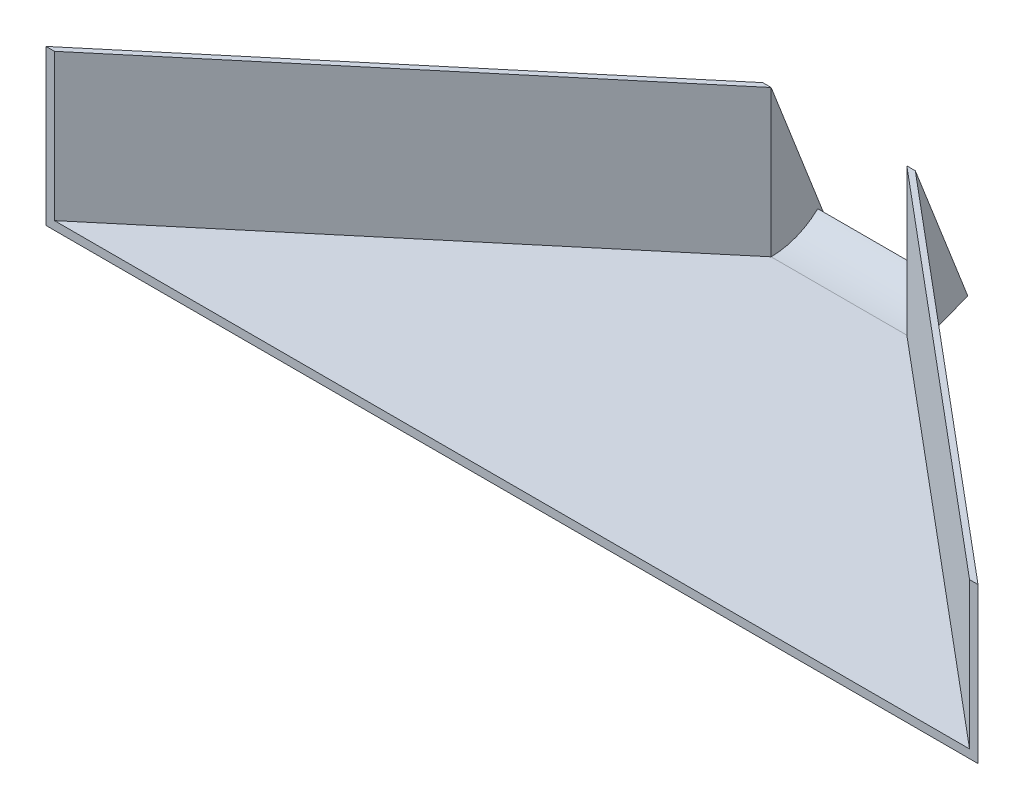
from build123d import *

# Parameters (mm, degrees)
BOSS_EXTRUDE1_DEPTH   = 2.7686
BOSS_EXTRUDE2_START   = -2.7686
BOSS_EXTRUDE2_DEPTH   = 50.8
BOSS_EXTRUDE2_2_DEPTH = 50.8
SKETCH4_W             = 2.7686
SKETCH4_H             = 50.8
BOSS_EXTRUDE3_DEPTH   = 25.4
CUT_EXTRUDE1_DEPTH    = 47.2186
BOSS_EXTRUDE6_DEPTH   = 44.45


with BuildPart() as part:
    # Sketch1 → Boss-Extrude1 (new body)
    with BuildSketch(Plane(origin=(0, 0, 0), x_dir=(1, 0, 0), z_dir=(0, 1, 0))):
        Polygon((0, 0), (44.45, 0), (172.085, -107.098481425), (-127.635, -107.098481425), align=None)
    extrude(amount=BOSS_EXTRUDE1_DEPTH)



with BuildPart() as body_2:
    # Sketch2 → Boss-Extrude2 (new body)
    with BuildSketch(Plane(origin=(0, 2.7686, 0), x_dir=(1, 0, 0), z_dir=(0, 1, 0)).offset(BOSS_EXTRUDE2_START)):
        Polygon((0, 0), (-127.635, -107.098481425), (-130.4036, -107.098481425), (-2.7686, 0), align=None)
    extrude(amount=BOSS_EXTRUDE2_DEPTH)


with BuildPart() as body_3:
    # Sketch2 → Boss-Extrude2 2 (new body)
    with BuildSketch(Plane(origin=(0, 2.7686, 0), x_dir=(1, 0, 0), z_dir=(0, 1, 0)).offset(BOSS_EXTRUDE2_START)):
        Polygon((44.45, 0), (47.2186, 0), (174.8536, -107.098481425), (172.085, -107.098481425), align=None)
    extrude(amount=BOSS_EXTRUDE2_2_DEPTH)


with BuildPart() as part_1:
    add(part.part)

    add(body_3.part)  # Boss-Extrude3 merges body 3
    # Sketch4 → Boss-Extrude3 (add)
    with BuildSketch(Plane(origin=(0, 0, 0), x_dir=(-1, 0, 0), z_dir=(0, 0, -1))):
        with Locations((-45.8343, 25.4)):
            Rectangle(SKETCH4_W, SKETCH4_H)
    boss_extrude3 = extrude(amount=BOSS_EXTRUDE3_DEPTH)

    # Sketch5 → Cut-Extrude1 (cut)
    with BuildSketch(Plane(origin=(47.2186, 0, 0), x_dir=(0, 0, -1), z_dir=(1, 0, 0))):
        Polygon((17.186035514, 6.697089394), (0, 0), (25.4, 0), (25.4, 14.244871038), (25.4, 50.8), (0, 50.8), align=None)
    cut_extrude1 = extrude(amount=-CUT_EXTRUDE1_DEPTH, mode=Mode.SUBTRACT)


    add(body_2.part)  # Boss-Extrude6 merges body 2
    # Sketch10 → Boss-Extrude6 (add)
    with BuildSketch(Plane.ZY.offset(-44.45)):
        with BuildLine():
            Line((-17.186035514, 6.697089394), (-15.298135688, 8.75161917))
            ThreePointArc((-15.298135688, 8.75161917), (-8.213243481, 4.317554379), (0, 2.7686))
            Line((0, 2.7686), (0, 0))
            Line((0, 0), (-17.186035514, 6.697089394))
        make_face()
    extrude(amount=BOSS_EXTRUDE6_DEPTH)

    # Mirror1: Boss-Extrude3 across plane
    add(boss_extrude3.mirror(Plane.ZY.offset(-22.225)))

    # Mirror2: Cut-Extrude1 across plane
    add(cut_extrude1.mirror(Plane.ZY.offset(-22.225)), mode=Mode.SUBTRACT)


solid = part_1.part
